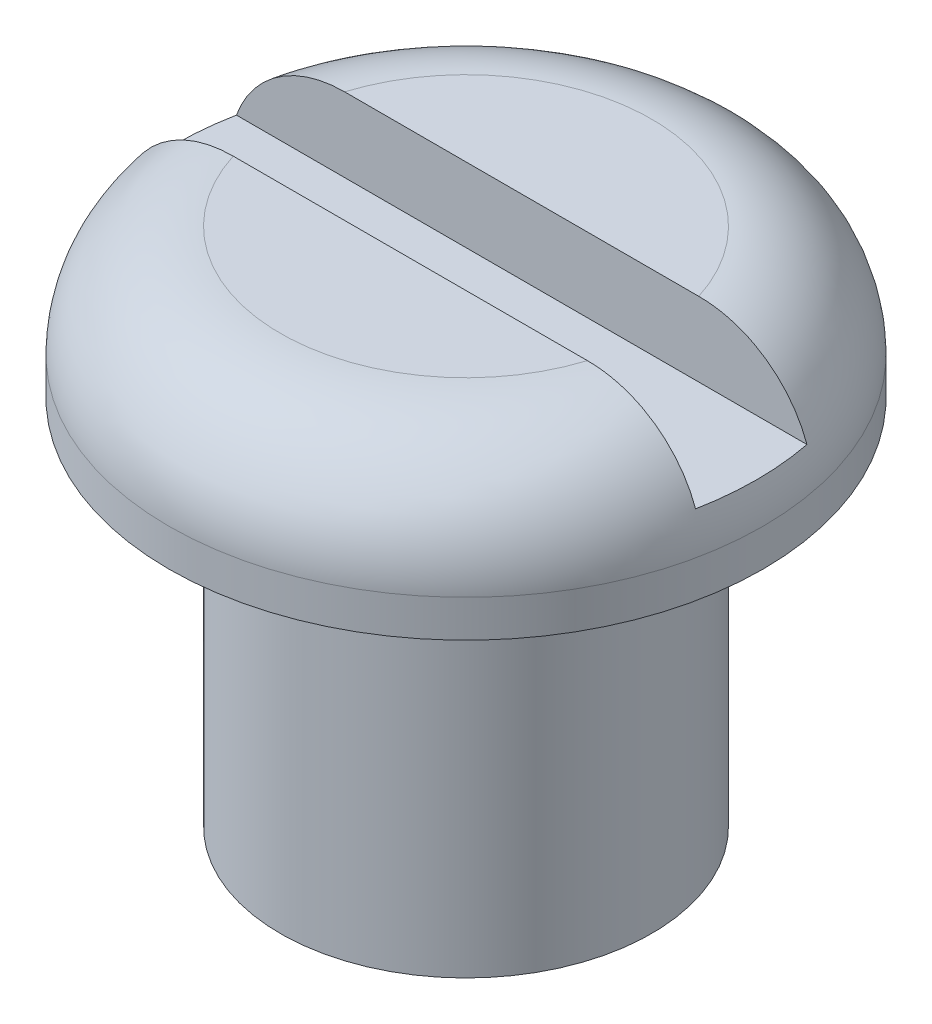
from build123d import *

# Parameters (mm, degrees)
ESBO_O2_W             = 8
ESBO_O2_H             = 1
CORTE_EXTRUS_O1_DEPTH = 0.75


with BuildPart() as part:
    # Esboço1 → Revolução1 (revolve)
    with BuildSketch(Plane.XY):
        with BuildLine():
            Line((0, 0), (2.5, 0))
            Line((2.5, 0), (2.5, 5))
            Line((2.5, 5), (4, 5))
            Line((4, 5), (4, 5.5))
            ThreePointArc((4, 5.5), (3.560660172, 6.560660172), (2.5, 7))
            Line((2.5, 7), (0, 7))
            Line((0, 7), (0, 0))
        make_face()
    revolve(axis=Axis((0, 7, 0), (0, -1, 0)))

    # Esboço2 → Corte-extrusão1 (cut, symmetric)
    with BuildSketch(Plane.XY):
        with Locations((0, 6.5)):
            Rectangle(ESBO_O2_W, ESBO_O2_H)
    extrude(amount=CORTE_EXTRUS_O1_DEPTH, both=True, mode=Mode.SUBTRACT)


solid = part.part
